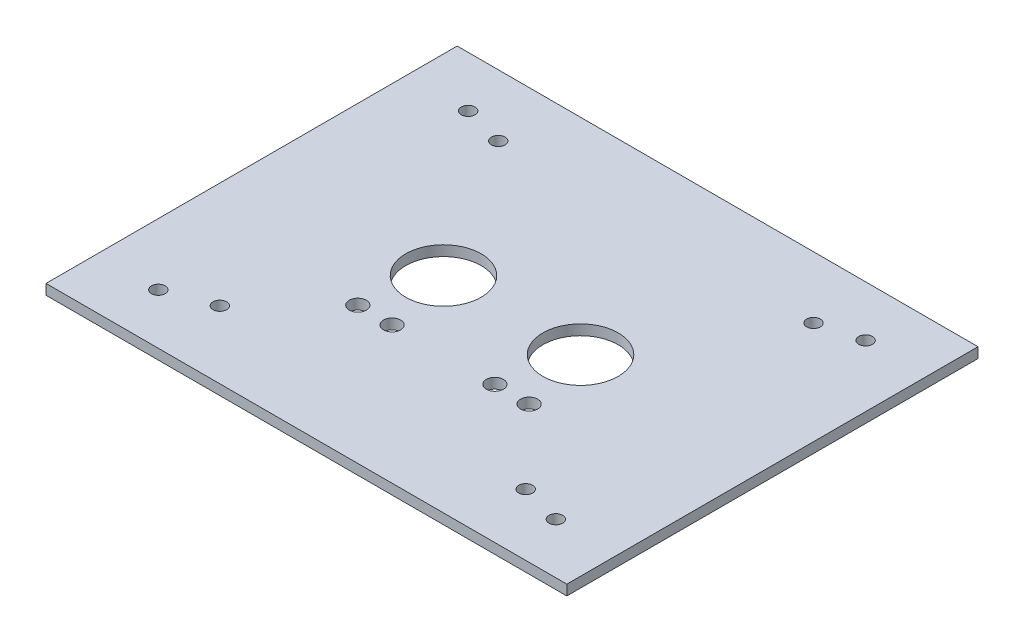
from build123d import *

# Parameters (mm, degrees)
SKETCH1_W           = 152
SKETCH1_H           = 120
SKETCH1_R           = 2.5
SKETCH1_R_2         = 11
BOSS_EXTRUDE1_DEPTH = 3
SKETCH2_R           = 2
CUT_EXTRUDE1_DEPTH  = 4


with BuildPart() as part:
    # Sketch1 → Boss-Extrude1 (new body)
    with BuildSketch(Plane(origin=(0, 0, 0), x_dir=(1, 0, 0), z_dir=(0, 1, 0))):
        with Locations((49.311456102, 37.795094937)):
            Rectangle(SKETCH1_W, SKETCH1_H)
        with Locations((24.311456102, 17.795094937)):
            Circle(SKETCH1_R, mode=Mode.SUBTRACT)
        with Locations((34.311456102, 17.795094937)):
            Circle(SKETCH1_R, mode=Mode.SUBTRACT)
        with Locations((64.311456102, 17.795094937)):
            Circle(SKETCH1_R, mode=Mode.SUBTRACT)
        with Locations((74.311456102, 17.795094937)):
            Circle(SKETCH1_R, mode=Mode.SUBTRACT)
        with Locations((29.311456102, 37.795094937)):
            Circle(SKETCH1_R_2, mode=Mode.SUBTRACT)
        with Locations((69.311456102, 37.795094937)):
            Circle(SKETCH1_R_2, mode=Mode.SUBTRACT)
    extrude(amount=BOSS_EXTRUDE1_DEPTH)

    # Sketch2 → Cut-Extrude1 (cut, through all)
    with BuildSketch(Plane.XZ):
        with Locations((4.327840203, 2.482417514)):
            Circle(SKETCH2_R)
        with Locations((95.311456102, -79.795094937)):
            Circle(SKETCH2_R)
        with Locations((3.311456102, -79.795094937)):
            Circle(SKETCH2_R)
        with Locations((-8.688543898, -82.997135966)):
            Circle(SKETCH2_R)
        with Locations((95.311456102, 4.204905063)):
            Circle(SKETCH2_R)
        with Locations((107.311456102, -82.997135966)):
            Circle(SKETCH2_R)
        with Locations((-8.688543898, 7.406946092)):
            Circle(SKETCH2_R)
        with Locations((107.311456102, 7.406946092)):
            Circle(SKETCH2_R)
    extrude(amount=-CUT_EXTRUDE1_DEPTH, mode=Mode.SUBTRACT)


solid = part.part
